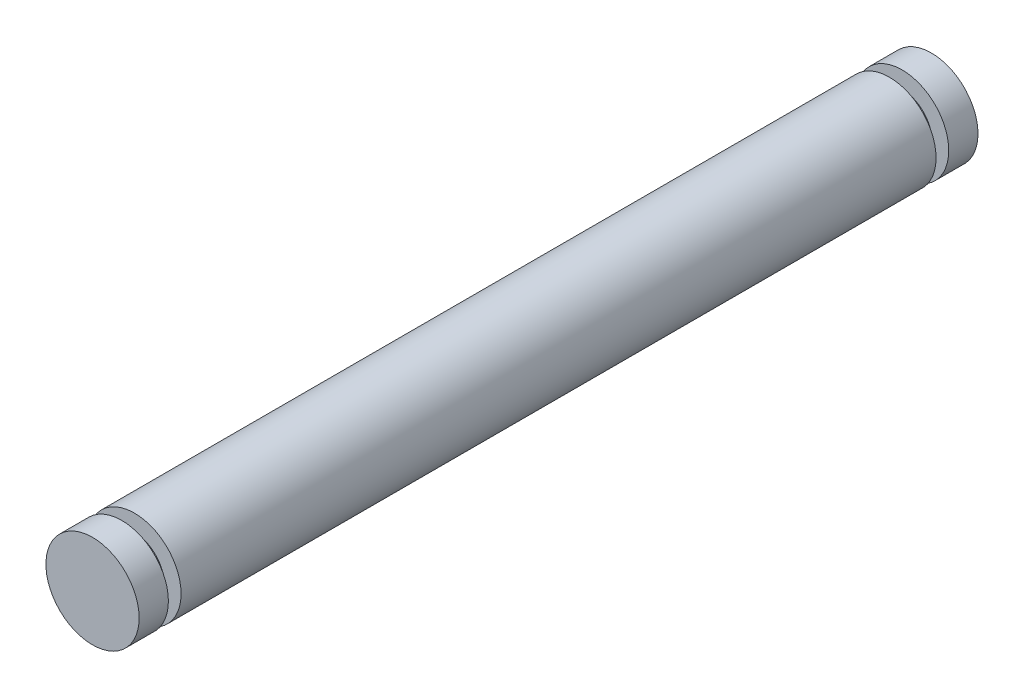
from build123d import *

# Parameters (mm, degrees)
SKETCH1_R           = 2.5
BOSS_EXTRUDE1_DEPTH = 45
SKETCH2_W           = 0.68
SKETCH2_H           = 0.9


with BuildPart() as part:
    # Sketch1 → Boss-Extrude1 (new body)
    with BuildSketch(Plane.XY):
        Circle(SKETCH1_R)
    extrude(amount=-BOSS_EXTRUDE1_DEPTH)

    # Sketch2 → Cut-Revolve1 (revolve, cut)
    with BuildSketch(Plane(origin=(0, 0, 0), x_dir=(0, 0, -1), z_dir=(1, 0, 0))):
        with Locations((1.91, 2.05)):
            Rectangle(SKETCH2_W, SKETCH2_H)
        with Locations((43.09, 2.05)):
            Rectangle(SKETCH2_W, SKETCH2_H)
    revolve(axis=Axis((0, 0, 0), (0, 0, -1)), mode=Mode.SUBTRACT)


solid = part.part
